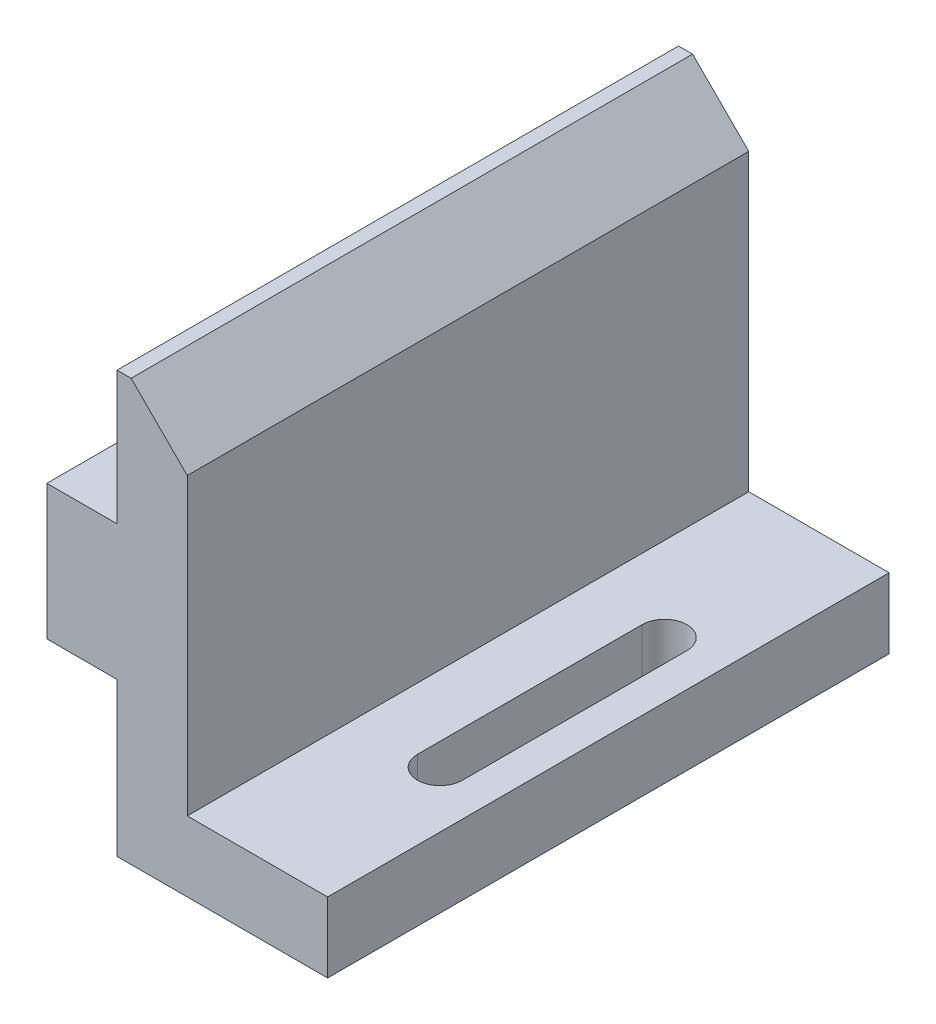
from build123d import *

# Parameters (mm, degrees)
BOSS_EXTRUDE1_DEPTH = 12.7
SKETCH2_W           = 3.175
SKETCH2_H           = 6.096
BOSS_EXTRUDE2_DEPTH = 12.7
CUT_EXTRUDE1_DEPTH  = 4.175
CHAMFER1_SIZE       = 2.54


with BuildPart() as part:
    # Sketch1 → Boss-Extrude1 (new body, symmetric)
    with BuildSketch(Plane.XY):
        Polygon((0, 0), (9.525, 0), (9.525, 3.175), (3.175, 3.175), (3.175, 19.05), (0, 19.05), align=None)
    extrude(amount=BOSS_EXTRUDE1_DEPTH, both=True)

    # Sketch2 → Boss-Extrude2 (add, symmetric)
    with BuildSketch(Plane.XY):
        with Locations((-1.5875, 9.9822)):
            Rectangle(SKETCH2_W, SKETCH2_H)
    extrude(amount=BOSS_EXTRUDE2_DEPTH, both=True)

    # Sketch3 → Cut-Extrude1 (cut, through all)
    with BuildSketch(Plane(origin=(0, 3.175, 0), x_dir=(1, 0, 0), z_dir=(0, 1, 0))):
        with BuildLine():
            Line((8.001, 5.08), (8.001, -5.08))
            ThreePointArc((8.001, -5.08), (6.985, -6.096), (5.969, -5.08))
            Line((5.969, -5.08), (5.969, 5.08))
            ThreePointArc((5.969, 5.08), (6.985, 6.096), (8.001, 5.08))
        make_face()
    extrude(amount=-CUT_EXTRUDE1_DEPTH, mode=Mode.SUBTRACT)

    # Chamfer1
    chamfer1_edges = [part.edges().sort_by_distance(p)[0] for p in [
        (3.175, 19.05, 0),
    ]]
    chamfer(chamfer1_edges, length=CHAMFER1_SIZE)


solid = part.part
